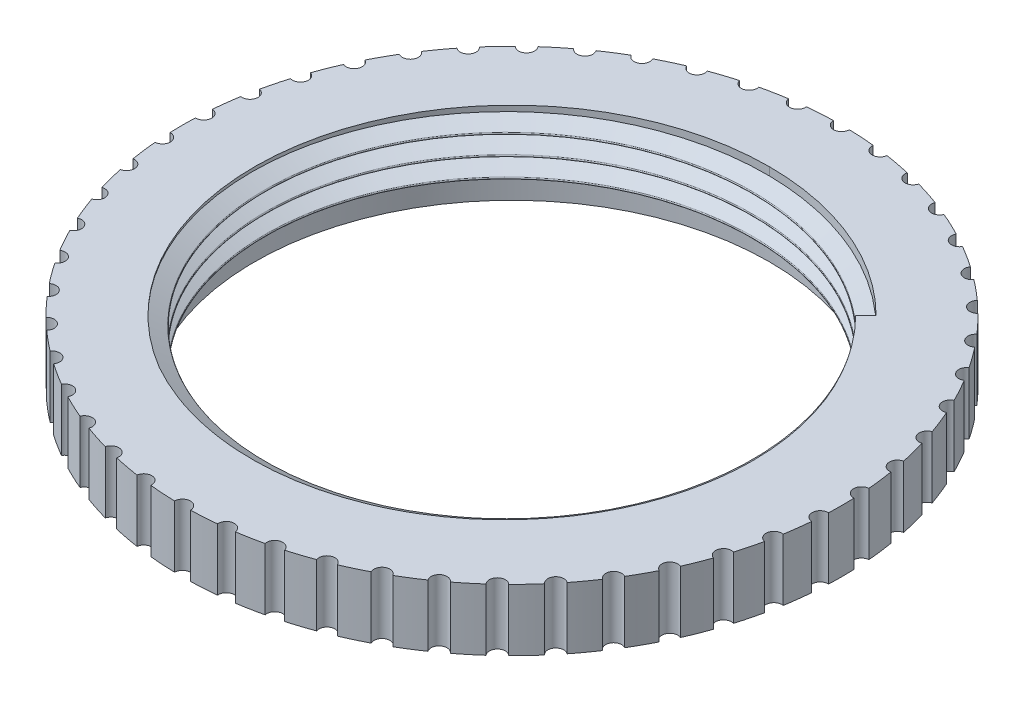
from build123d import *

# Parameters (mm, degrees)
SKIZZE1_R                       = 16
SKIZZE1_R_2                     = 12.5
AUFSATZ_LINEAR_AUSTRAGEN1_DEPTH = 3
AUSTRAGUNG1_PITCH               = 0.94
AUSTRAGUNG1_HEIGHT              = 3.055
AUSTRAGUNG1_RADIUS              = 12.5
AUSTRAGUNG1_START_ANGLE         = 45
SKIZZE7_R                       = 13.218662406
SCHNITT_LINEAR_AUSTRAGEN2_DEPTH = 10
SKIZZE8_R                       = 14.014999136
SCHNITT_LINEAR_AUSTRAGEN3_DEPTH = 10
VERRUNDUNG1_R                   = 0.05
SKIZZE9_R                       = 13.809639419
SKIZZE9_R_2                     = 12.5
AUFSATZ_LINEAR_AUSTRAGEN3_DEPTH = 1
SKIZZE10_R                      = 0.387066934
SCHNITT_LINEAR_AUSTRAGEN4_DEPTH = 11
KREISMUSTER2_COUNT              = 50


with BuildPart() as part:
    # Skizze1 → Aufsatz-Linear austragen1 (new body)
    with BuildSketch(Plane(origin=(0, 0, 0), x_dir=(1, 0, 0), z_dir=(0, 1, 0))):
        Circle(SKIZZE1_R)
        Circle(SKIZZE1_R_2, mode=Mode.SUBTRACT)
    extrude(amount=AUFSATZ_LINEAR_AUSTRAGEN1_DEPTH)

    # Austragung1: sweep along a helix
    with BuildLine() as austragung1_path:
        add(Helix(AUSTRAGUNG1_PITCH, AUSTRAGUNG1_HEIGHT, AUSTRAGUNG1_RADIUS, center=(0, 3, 0), direction=(0, -1, 0), mode=Mode.PRIVATE).rotate(Axis((0, 3, 0), (0, -1, 0)), AUSTRAGUNG1_START_ANGLE))
    # Skizze6 → Austragung1 (sweep)
    with BuildSketch(Plane(origin=(0, 0, 0), x_dir=(0.707106781, 0, -0.707106781), z_dir=(0.707106781, 0, 0.707106781))):
        Polygon((11.75, 3), (12.875, 2.350480947), (12.875, 3.649519053), align=None)
    sweep(path=austragung1_path.line, is_frenet=True)

    # Skizze7 → Schnitt-Linear austragen2 (cut)
    with BuildSketch(Plane(origin=(0, 3, 0), x_dir=(1, 0, 0), z_dir=(0, 1, 0))):
        Circle(SKIZZE7_R)
    extrude(amount=SCHNITT_LINEAR_AUSTRAGEN2_DEPTH, mode=Mode.SUBTRACT)

    # Skizze8 → Schnitt-Linear austragen3 (cut)
    with BuildSketch(Plane.XZ):
        Circle(SKIZZE8_R)
    extrude(amount=SCHNITT_LINEAR_AUSTRAGEN3_DEPTH, mode=Mode.SUBTRACT)

    # Verrundung1
    verrundung1_edges = [part.edges().sort_by_distance(p)[0] for p in [
        (-11.552061001, 1.499999945, 2.147709407),
    ]]
    fillet(verrundung1_edges, radius=VERRUNDUNG1_R)

    # Skizze9 → Aufsatz-Linear austragen3 (add)
    with BuildSketch(Plane.XZ):
        Circle(SKIZZE9_R)
        Circle(SKIZZE9_R_2, mode=Mode.SUBTRACT)
    extrude(amount=AUFSATZ_LINEAR_AUSTRAGEN3_DEPTH)

    # Skizze10 → Schnitt-Linear austragen4 (cut)
    with BuildSketch(Plane(origin=(0, 3, 0), x_dir=(1, 0, 0), z_dir=(0, 1, 0))):
        with Locations((0, 16)):
            Circle(SKIZZE10_R)
    schnitt_linear_austragen4 = extrude(amount=-SCHNITT_LINEAR_AUSTRAGEN4_DEPTH, mode=Mode.SUBTRACT)

    # Kreismuster2: Schnitt-Linear austragen4 ×50 about axis
    kreismuster2_axis = Axis((0, 0, 0), (0, 1, 0))
    for i in range(1, KREISMUSTER2_COUNT):
        add(schnitt_linear_austragen4.rotate(kreismuster2_axis, i * 360 / KREISMUSTER2_COUNT), mode=Mode.SUBTRACT)


solid = part.part
